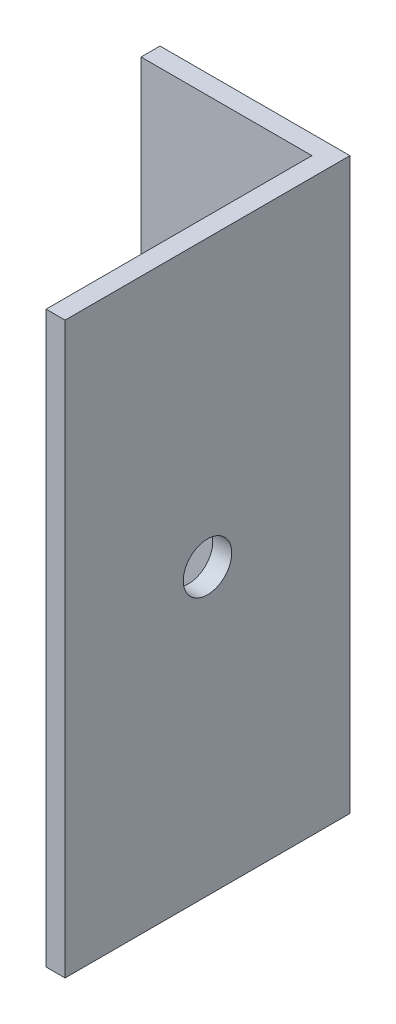
from build123d import *

# Parameters (mm, degrees)
BOSS_EXTRUDE1_DEPTH = 60
SKETCH2_R           = 2.55
CUT_EXTRUDE1_DEPTH  = 60


with BuildPart() as part:
    # Sketch1 → Boss-Extrude1 (new body)
    with BuildSketch(Plane(origin=(0, 0, 0), x_dir=(1, 0, 0), z_dir=(0, 1, 0))):
        Polygon((-9.236166208, 0), (10.763833792, 0), (10.763833792, -30), (8.763833792, -30), (8.763833792, -2), (-9.236166208, -2), align=None)
    extrude(amount=BOSS_EXTRUDE1_DEPTH)

    # Sketch2 → Cut-Extrude1 (cut)
    with BuildSketch(Plane(origin=(10.763833792, 0, 0), x_dir=(0, 0, -1), z_dir=(1, 0, 0))):
        with Locations((-15, 30)):
            Circle(SKETCH2_R)
    extrude(amount=-CUT_EXTRUDE1_DEPTH, mode=Mode.SUBTRACT)


solid = part.part
